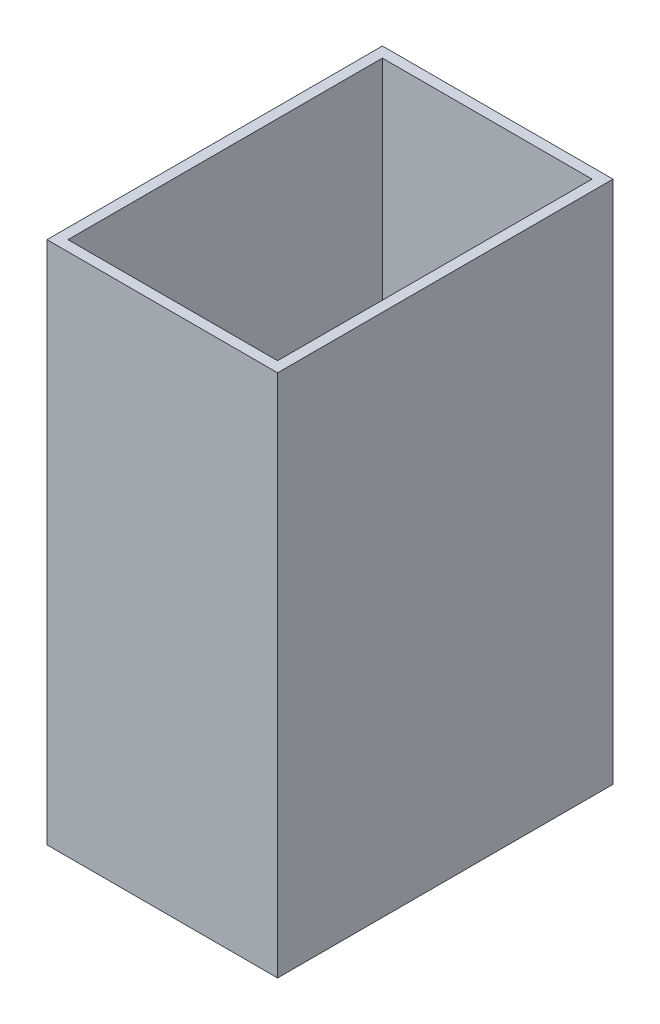
from build123d import *

# Parameters (mm, degrees)
SKETCH_2_W      = 220
SKETCH_2_H      = 320
SKETCH_2_W_2    = 200
SKETCH_2_H_2    = 300
EXTRUDE_2_DEPTH = 500


with BuildPart() as part:
    # 草图2 → 凸台-拉伸2 (new body)
    with BuildSketch(Plane(origin=(0, 0, 0), x_dir=(1, 0, 0), z_dir=(0, 1, 0))):
        Rectangle(SKETCH_2_W, SKETCH_2_H)
        Rectangle(SKETCH_2_W_2, SKETCH_2_H_2, mode=Mode.SUBTRACT)
    extrude(amount=EXTRUDE_2_DEPTH)


solid = part.part
